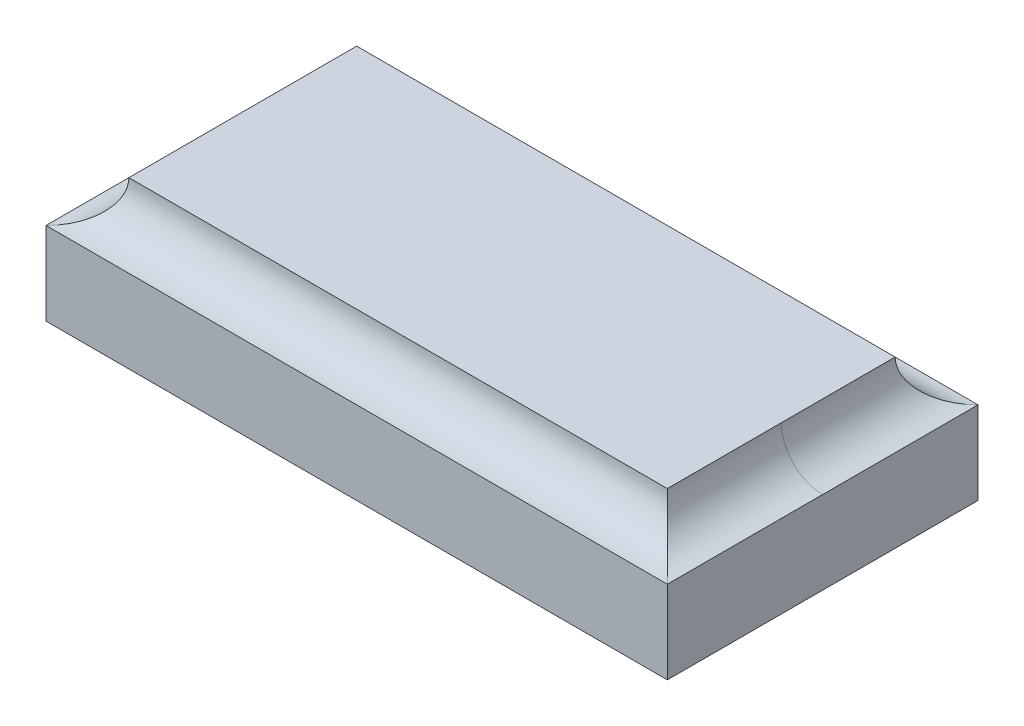
from build123d import *

# Parameters (mm, degrees)
SKETCH2_W           = 300
SKETCH2_H           = 150
BOSS_EXTRUDE1_DEPTH = 60
SKETCH3_R           = 20


with BuildPart() as part:
    # Sketch2 → Boss-Extrude1 (new body)
    with BuildSketch(Plane(origin=(0, 0, 0), x_dir=(1, 0, 0), z_dir=(0, 1, 0))):
        Rectangle(SKETCH2_W, SKETCH2_H)
    extrude(amount=BOSS_EXTRUDE1_DEPTH)

    # Cut-Sweep3: sweep along a path in Sketch4
    with BuildLine(Plane(origin=(0, 60, 0), x_dir=(1, 0, 0), z_dir=(0, 1, 0))) as cut_sweep3_path:
        Line((-150, 75), (-150, -75))
        Line((-150, -75), (150, -75))
        Line((150, -75), (150, 75))
        Line((150, 75), (-150, 75))
    # Sketch3 → Cut-Sweep3 (sweep, cut)
    with BuildSketch(Plane.XY):
        with Locations((150, 60)):
            Circle(SKETCH3_R)
    sweep(path=cut_sweep3_path.line, transition=Transition.RIGHT, mode=Mode.SUBTRACT)


solid = part.part
